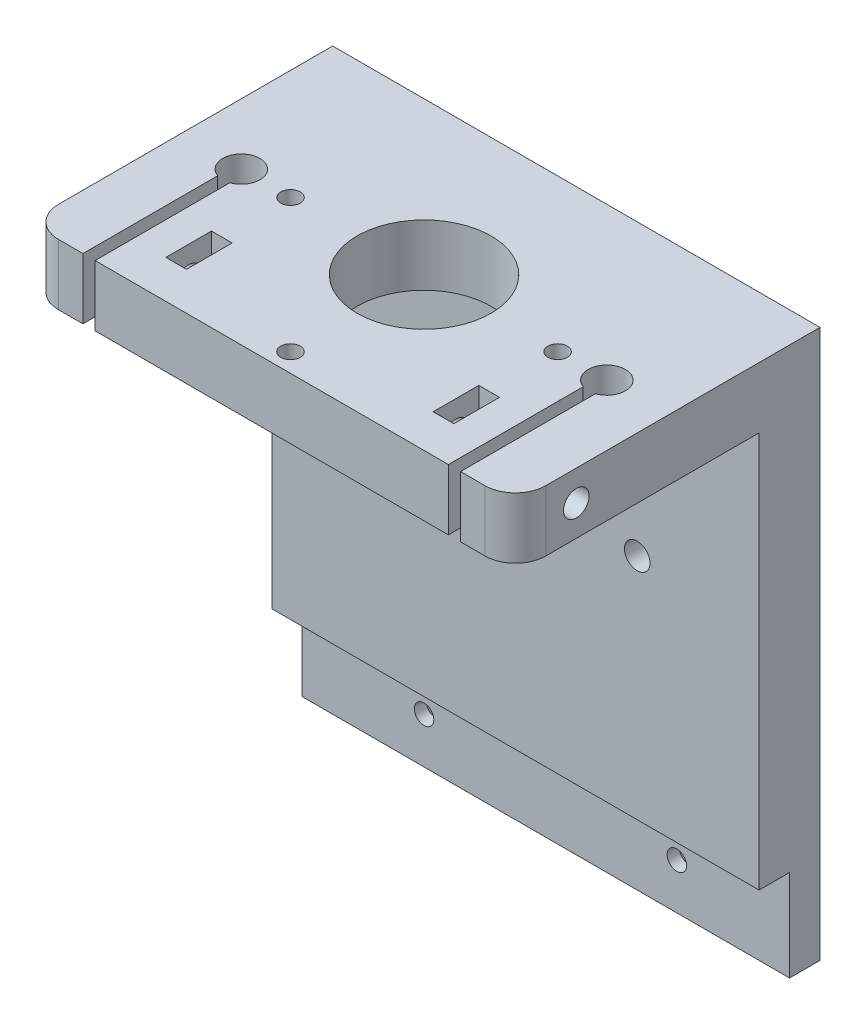
from build123d import *

# Parameters (mm, degrees)
SKETCH_1_W           = 80
SKETCH_1_H           = 150
EXTRUDE_1_DEPTH      = 10
SKETCH_4_R           = 11.25
EXTRUDE_3_DEPTH      = 10
SKETCH_5_R           = 11.25
SKETCH_5_R_2         = 5
EXTRUDE_4_DEPTH      = 4
SKETCH_6_R           = 2.1
CUT_EXTRUDE_1_DEPTH  = 24
SKETCH_7_W           = 3.4
SKETCH_7_H           = 7.5
CUT_EXTRUDE_2_DEPTH  = 24
SKETCH_8_R           = 2.1
CUT_EXTRUDE_3_DEPTH  = 24
SKETCH_9_W           = 80
SKETCH_9_H           = 40
SKETCH_9_R           = 11
SKETCH_9_R_2         = 1.6
EXTRUDE_5_DEPTH      = 10
FILLET_1_R           = 5
SKETCH_10_W          = 3.4
SKETCH_10_H          = 7.5
CUT_EXTRUDE_5_DEPTH  = 10
SKETCH_11_R          = 2.1
CUT_EXTRUDE_6_DEPTH  = 24
SKETCH_12_R          = 2.1
CUT_EXTRUDE_7_DEPTH  = 24
SKETCH_14_W          = 4
SKETCH_14_H          = 2
CUT_EXTRUDE_9_DEPTH  = 10
SKETCH_16_R          = 2.1
CUT_EXTRUDE_10_DEPTH = 11
CUT_EXTRUDE_12_DEPTH = 81
CUT_EXTRUDE_13_DEPTH = 3
SKETCH_20_R          = 1.6
CUT_EXTRUDE_15_DEPTH = 20


with BuildPart() as part:
    # 草圖1 → 填料-伸長1 (new body)
    with BuildSketch(Plane.XY):
        Rectangle(SKETCH_1_W, SKETCH_1_H)
    extrude(amount=EXTRUDE_1_DEPTH)

    # 草圖4 → 填料-伸長3 (add)
    with BuildSketch(Plane.XZ.offset(75)):
        with BuildLine():
            ThreePointArc((-6, 49), (0, 43), (6, 49))
            Line((6, 49), (6, 50))
            Line((6, 50), (29, 50))
            Line((29, 50), (29, 27.881405907))
            ThreePointArc((29, 27.881405907), (30, 21.95), (31, 27.881405907))
            Line((31, 27.881405907), (31, 50))
            Line((31, 50), (40, 50))
            Line((40, 50), (40, 10))
            Line((40, 10), (-40, 10))
            Line((-40, 10), (-40, 50))
            Line((-40, 50), (-31, 50))
            Line((-31, 50), (-31, 27.881405907))
            ThreePointArc((-31, 27.881405907), (-30, 21.95), (-29, 27.881405907))
            Line((-29, 27.881405907), (-29, 50))
            Line((-29, 50), (-6, 50))
            Line((-6, 50), (-6, 49))
        make_face()
        with Locations((0, 25)):
            Circle(SKETCH_4_R, mode=Mode.SUBTRACT)
    extrude(amount=-EXTRUDE_3_DEPTH)

    # 草圖5 → 填料-伸長4 (add)
    with BuildSketch(Plane.XZ.offset(75)):
        with Locations((0, 25)):
            Circle(SKETCH_5_R)
        with Locations((0, 25)):
            Circle(SKETCH_5_R_2, mode=Mode.SUBTRACT)
    extrude(amount=-EXTRUDE_4_DEPTH)

    # 草圖6 → 除料-伸長1 (cut)
    with BuildSketch(Plane(origin=(40, 0, 0), x_dir=(0, 0, -1), z_dir=(1, 0, 0))):
        with Locations((-40, -70)):
            Circle(SKETCH_6_R)
    extrude(amount=-CUT_EXTRUDE_1_DEPTH, mode=Mode.SUBTRACT)

    # 草圖7 → 除料-伸長2 (cut)
    with BuildSketch(Plane.XZ.offset(75)):
        with Locations((-21.943112787, 40)):
            Rectangle(SKETCH_7_W, SKETCH_7_H)
        with Locations((21.943112787, 40)):
            Rectangle(SKETCH_7_W, SKETCH_7_H)
    extrude(amount=-CUT_EXTRUDE_2_DEPTH, mode=Mode.SUBTRACT)

    # 草圖8 → 除料-伸長3 (cut)
    with BuildSketch(Plane.ZY.offset(40)):
        with Locations((40, -70)):
            Circle(SKETCH_8_R)
    extrude(amount=-CUT_EXTRUDE_3_DEPTH, mode=Mode.SUBTRACT)

    # 草圖9 → 填料-伸長5 (add)
    with BuildSketch(Plane(origin=(0, 75, 0), x_dir=(1, 0, 0), z_dir=(0, 1, 0))):
        with Locations((0, -30)):
            Rectangle(SKETCH_9_W, SKETCH_9_H)
        with Locations((0, -25)):
            Circle(SKETCH_9_R, mode=Mode.SUBTRACT)
        with Locations((-21.920310217, -25)):
            Circle(SKETCH_9_R_2, mode=Mode.SUBTRACT)
        with Locations((0, -46.920310217)):
            Circle(SKETCH_9_R_2, mode=Mode.SUBTRACT)
        with Locations((21.920310217, -25)):
            Circle(SKETCH_9_R_2, mode=Mode.SUBTRACT)
    extrude(amount=-EXTRUDE_5_DEPTH)

    # 圓角1
    fillet_1_edges = [part.edges().sort_by_distance(p)[0] for p in [
        (40, 70, 50),
        (-40, 70, 50),
        (40, -70, 50),
        (-40, -70, 50),
    ]]
    fillet(fillet_1_edges, radius=FILLET_1_R)

    # 草圖10 → 除料-伸長5 (cut)
    with BuildSketch(Plane(origin=(0, 75, 0), x_dir=(1, 0, 0), z_dir=(0, 1, 0))):
        with BuildLine():
            Line((-30.992105359, -72.117230176), (-29, -72.117230176))
            Line((-29, -72.117230176), (-29, -27.881405907))
            ThreePointArc((-29, -27.881405907), (-30.004176302, -21.950002859), (-30.992105359, -27.884133658))
            Line((-30.992105359, -27.884133658), (-30.992105359, -72.117230176))
        make_face()
        with BuildLine():
            Line((29.001577897, -72.118320527), (31, -72.118320527))
            Line((31, -72.118320527), (31, -27.881405907))
            ThreePointArc((31, -27.881405907), (29.999164969, -21.950000114), (29.001577897, -27.881953036))
            Line((29.001577897, -27.881953036), (29.001577897, -72.118320527))
        make_face()
        with Locations((-21.943112787, -40)):
            Rectangle(SKETCH_10_W, SKETCH_10_H)
        with Locations((21.943112787, -40)):
            Rectangle(SKETCH_10_W, SKETCH_10_H)
    extrude(amount=-CUT_EXTRUDE_5_DEPTH, mode=Mode.SUBTRACT)

    # 草圖11 → 除料-伸長6 (cut)
    with BuildSketch(Plane(origin=(40, 0, 0), x_dir=(0, 0, -1), z_dir=(1, 0, 0))):
        with Locations((-40, 70)):
            Circle(SKETCH_11_R)
    extrude(amount=-CUT_EXTRUDE_6_DEPTH, mode=Mode.SUBTRACT)

    # 草圖12 → 除料-伸長7 (cut)
    with BuildSketch(Plane.ZY.offset(40)):
        with Locations((40, 70)):
            Circle(SKETCH_12_R)
    extrude(amount=-CUT_EXTRUDE_7_DEPTH, mode=Mode.SUBTRACT)

    # 草圖14 → 除料-伸長9 (cut)
    with BuildSketch(Plane.XZ.offset(75)):
        with Locations((-12, 46)):
            Rectangle(SKETCH_14_W, SKETCH_14_H)
        with Locations((12, 46)):
            Rectangle(SKETCH_14_W, SKETCH_14_H)
    extrude(amount=-CUT_EXTRUDE_9_DEPTH, mode=Mode.SUBTRACT)

    # 草圖16 → 除料-伸長10 (cut, through all)
    with BuildSketch(Plane.XY.offset(10)):
        with Locations((-20, 37.5)):
            Circle(SKETCH_16_R)
        with Locations((20, 37.5)):
            Circle(SKETCH_16_R)
        with Locations((20, -37.5)):
            Circle(SKETCH_16_R)
        with Locations((-20, -37.5)):
            Circle(SKETCH_16_R)
    extrude(amount=-CUT_EXTRUDE_10_DEPTH, mode=Mode.SUBTRACT)

    # 草圖17 → 除料-伸長12 (cut, through all)
    with BuildSketch(Plane(origin=(40, 0, 0), x_dir=(0, 0, -1), z_dir=(1, 0, 0))):
        Polygon((-10, -15), (-13, -15), (-13, 0), (-5, 0), (-5, -15), (0, -15), (0, -75), (-50, -75), (-50, -65), (-10, -65), align=None)
    extrude(amount=-CUT_EXTRUDE_12_DEPTH, mode=Mode.SUBTRACT)

    # 草圖19 → 除料-伸長13 (cut)
    with BuildSketch(Plane(origin=(0, 0, 0), x_dir=(-1, 0, 0), z_dir=(0, 0, -1))):
        Polygon((-18.036462654, -7.5), (-19.768513462, -4.5), (-23.232615077, -4.5), (-24.964665884, -7.5), (-23.232615077, -10.5), (-19.768513462, -10.5), align=None)
        Polygon((23.464101615, -7.5), (21.732050808, -4.5), (18.267949192, -4.5), (16.535898385, -7.5), (18.267949192, -10.5), (21.732050808, -10.5), align=None)
    extrude(amount=-CUT_EXTRUDE_13_DEPTH, mode=Mode.SUBTRACT)

    # 草圖20 → 除料-伸長15 (cut)
    with BuildSketch(Plane(origin=(0, 0, 0), x_dir=(-1, 0, 0), z_dir=(0, 0, -1))):
        with Locations((-21.500564269, -7.5)):
            Circle(SKETCH_20_R)
        with Locations((20, -7.5)):
            Circle(SKETCH_20_R)
    extrude(amount=-CUT_EXTRUDE_15_DEPTH, mode=Mode.SUBTRACT)


solid = part.part
